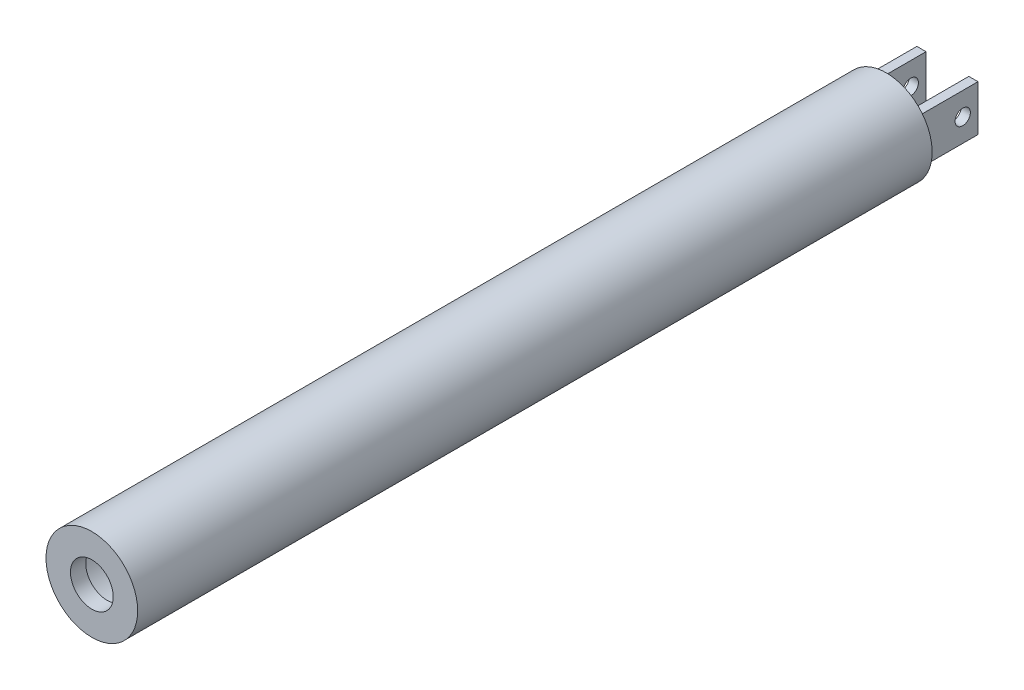
from build123d import *

# Parameters (mm, degrees)
SKETCH1_R                = 15
SKETCH1_R_2              = 13.5
BOSS_EXTRUDE1_DEPTH      = 250
SKETCH2_R                = 15
BOSS_EXTRUDE2_DEPTH      = 5
SKETCH3_R                = 15
SKETCH3_R_2              = 7
BOSS_EXTRUDE3_DEPTH      = 5
SKETCH4_W                = 20
SKETCH4_H                = 15
SKETCH4_R                = 2.5
BOSS_EXTRUDE4_DEPTH      = 10
BOSS_EXTRUDE4_DEPTH_BACK = 10
SKETCH5_W                = 14
SKETCH5_H                = 15
CUT_EXTRUDE1_DEPTH       = 20


with BuildPart() as part:
    # Sketch1 → Boss-Extrude1 (new body)
    with BuildSketch(Plane.XY):
        Circle(SKETCH1_R)
        Circle(SKETCH1_R_2, mode=Mode.SUBTRACT)
    extrude(amount=BOSS_EXTRUDE1_DEPTH)

    # Sketch2 → Boss-Extrude2 (add)
    with BuildSketch(Plane(origin=(0, 0, 0), x_dir=(-1, 0, 0), z_dir=(0, 0, -1))):
        Circle(SKETCH2_R)
    extrude(amount=BOSS_EXTRUDE2_DEPTH)

    # Sketch3 → Boss-Extrude3 (add)
    with BuildSketch(Plane.XY.offset(250)):
        Circle(SKETCH3_R)
        Circle(SKETCH3_R_2, mode=Mode.SUBTRACT)
    extrude(amount=BOSS_EXTRUDE3_DEPTH)

    # Sketch4 → Boss-Extrude4 (add, two sides)
    with BuildSketch(Plane(origin=(0, 0, 0), x_dir=(0, 0, -1), z_dir=(1, 0, 0))) as boss_extrude4_sk:
        with Locations((15, 0)):
            Rectangle(SKETCH4_W, SKETCH4_H)
        with Locations((20, 0)):
            Circle(SKETCH4_R, mode=Mode.SUBTRACT)
    extrude(amount=BOSS_EXTRUDE4_DEPTH)
    extrude(boss_extrude4_sk.sketch, amount=-BOSS_EXTRUDE4_DEPTH_BACK)

    # Sketch5 → Cut-Extrude1 (cut)
    with BuildSketch(Plane(origin=(0, 0, -25), x_dir=(-1, 0, 0), z_dir=(0, 0, -1))):
        Rectangle(SKETCH5_W, SKETCH5_H)
    extrude(amount=-CUT_EXTRUDE1_DEPTH, mode=Mode.SUBTRACT)


solid = part.part
